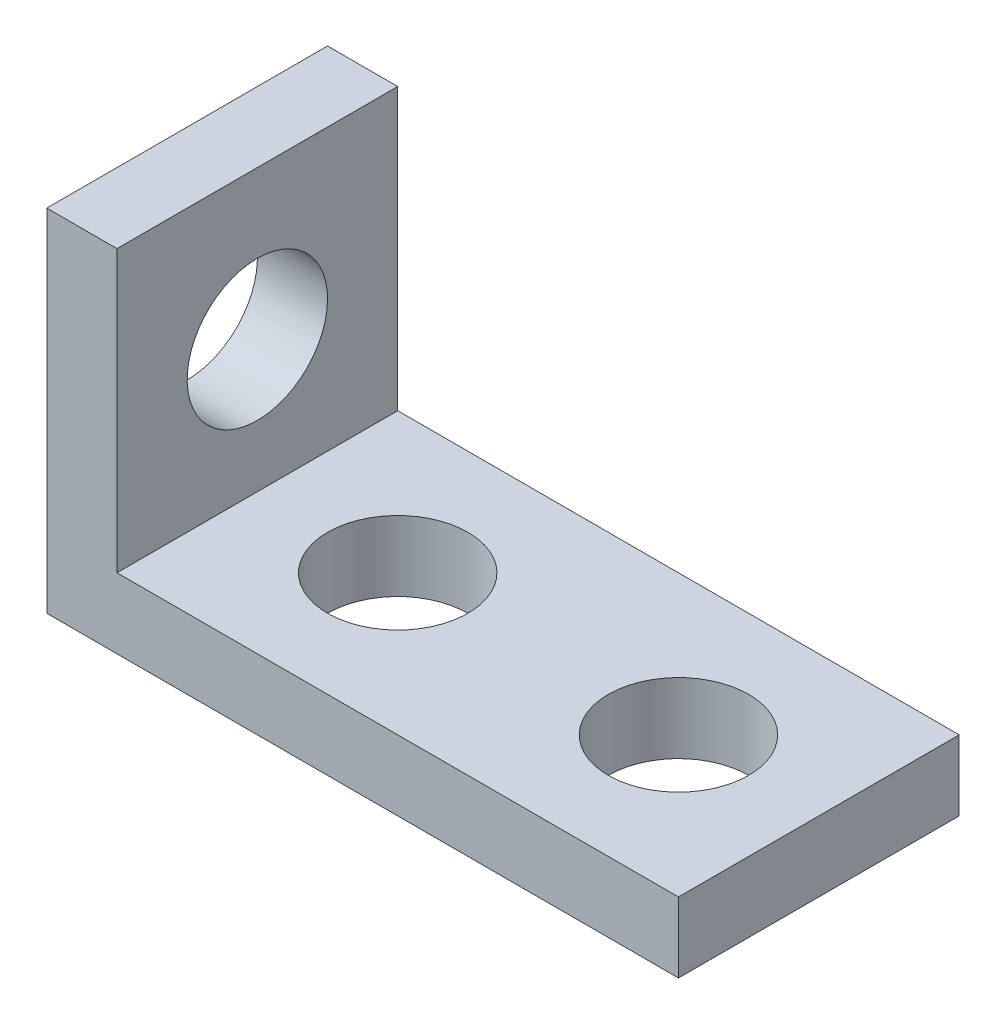
from build123d import *

# Parameters (mm, degrees)
BOSS_EXTRUDE1_DEPTH = 12.7
SKETCH2_R           = 3.175
CUT_EXTRUDE1_DEPTH  = 4.175
SKETCH3_R           = 3.175
CUT_EXTRUDE2_DEPTH  = 4.175


with BuildPart() as part:
    # Sketch1 → Boss-Extrude1 (new body)
    with BuildSketch(Plane.XY):
        Polygon((0, 0), (0, 15.875), (3.175, 15.875), (3.175, 3.175), (28.575, 3.175), (28.575, 0), align=None)
    extrude(amount=BOSS_EXTRUDE1_DEPTH)

    # Sketch2 → Cut-Extrude1 (cut, through all)
    with BuildSketch(Plane(origin=(0, 3.175, 0), x_dir=(1, 0, 0), z_dir=(0, 1, 0))):
        with Locations((9.525, -6.35)):
            Circle(SKETCH2_R)
        with Locations((22.225, -6.35)):
            Circle(SKETCH2_R)
    extrude(amount=-CUT_EXTRUDE1_DEPTH, mode=Mode.SUBTRACT)

    # Sketch3 → Cut-Extrude2 (cut, through all)
    with BuildSketch(Plane(origin=(3.175, 0, 0), x_dir=(0, 0, -1), z_dir=(1, 0, 0))):
        with Locations((-6.35, 9.144)):
            Circle(SKETCH3_R)
    extrude(amount=-CUT_EXTRUDE2_DEPTH, mode=Mode.SUBTRACT)


solid = part.part
